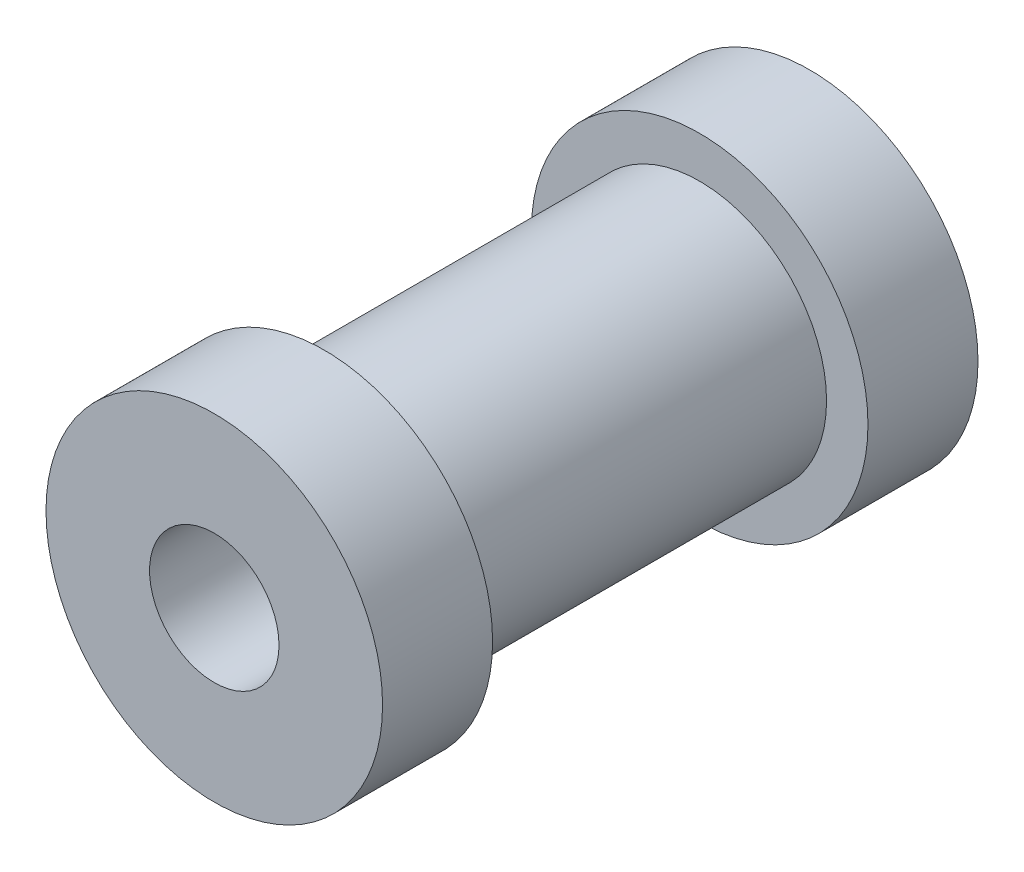
from build123d import *

# Parameters (mm, degrees)
SKETCH_3_W = 4.25
SKETCH_3_H = 1.6


with BuildPart() as part:
    # Эскиз2 → Повернуть1 (revolve)
    with BuildSketch(Plane(origin=(0, 0, 0), x_dir=(0, 0, -1), z_dir=(1, 0, 0))):
        Polygon((18.75, 0), (-4.25, 0), (-4.25, 6.5), (0, 6.5), (0, 4.9), (18.75, 4.9), align=None)
    revolve(axis=Axis((0, 0, 1000), (0, 0, -1)))

    # Эскиз5 → Отверстие обработанное метчиком M61 (revolve, cut)
    with BuildSketch(Plane(origin=(0, 0, 4.25), x_dir=(0, -1, 0), z_dir=(1, 0, 0))):
        Polygon((0, 0), (0, 18.502151548), (2.5, 17), (2.5, 0), align=None)
    revolve(axis=Axis((0, 0, 10.6), (0, 0, -1)), mode=Mode.SUBTRACT)

    # Эскиз7 → Отверстие обработанное метчиком M62 (revolve, cut)
    with BuildSketch(Plane(origin=(0, 0, -18.75), x_dir=(0, 1, 0), z_dir=(1, 0, 0))):
        Polygon((0, 0), (0, 18.502151548), (2.5, 17), (2.5, 0), align=None)
    revolve(axis=Axis((0, 0, -25.1), (0, 0, 1)), mode=Mode.SUBTRACT)


with BuildPart() as body_2:
    # Эскиз3 → Повернуть2 (revolve)
    with BuildSketch(Plane(origin=(0, 0, 0), x_dir=(0, 0, -1), z_dir=(1, 0, 0))):
        with Locations((16.625, 5.7)):
            Rectangle(SKETCH_3_W, SKETCH_3_H)
    revolve(axis=Axis((0, 0, 1000), (0, 0, -1)))


solid = Compound([part.part, body_2.part])
